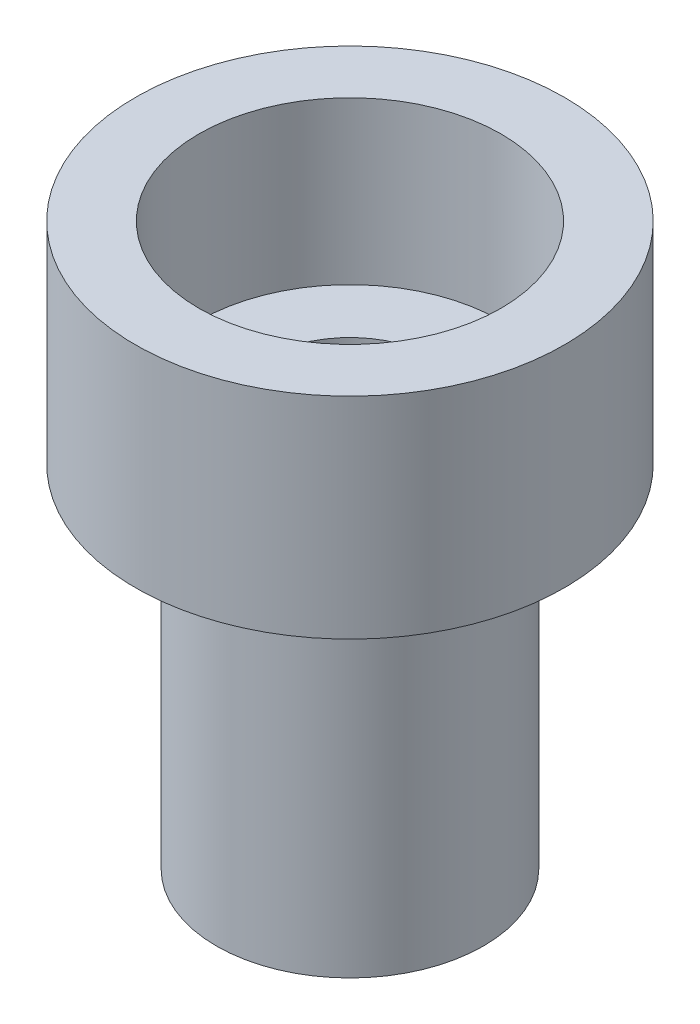
from build123d import *


with BuildPart() as part:
    # Sketch2 → Revolve1 (revolve)
    with BuildSketch(Plane.XY):
        Polygon((2.8, 10.4), (2.8, 7.4), (1.6, 7.4), (1.6, 0), (2.475, 0), (2.475, 6.5), (3.975, 6.5), (3.975, 10.4), align=None)
    revolve(axis=Axis((0, 0, 0), (0, 1, 0)))


solid = part.part
